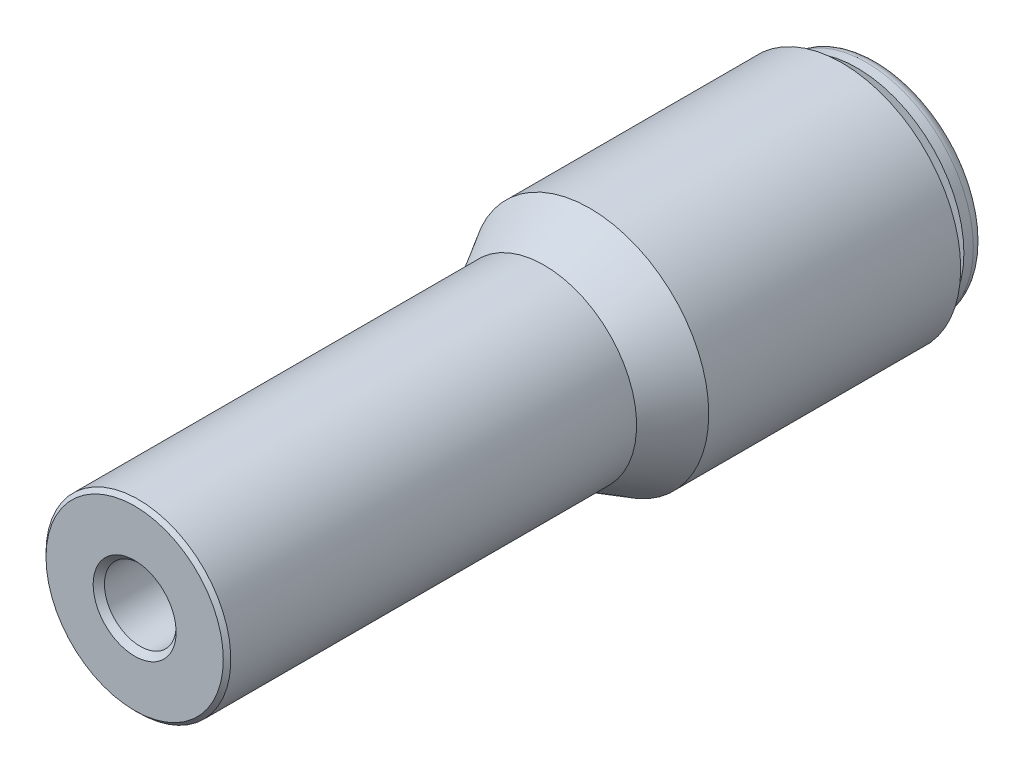
from build123d import *

# Parameters (mm, degrees)
CHAMFER1_SIZE      = 0.381
CUT_EXTRUDE1_REACH = 53.301
SKETCH2_R          = 6.35
SKETCH2_R_2        = 6.223


with BuildPart() as part:
    # Sketch1 → Revolve1 (revolve)
    with BuildSketch(Plane(origin=(0, 0, 0), x_dir=(0, 0, -1), z_dir=(1, 0, 0)), mode=Mode.PRIVATE) as revolve1_sk:
        with BuildLine():
            Line((23.622, 7.2009), (24.257, 7.2009))
            ThreePointArc((24.257, 7.2009), (24.795815367, 6.977715367), (25.019, 6.4389))
            Line((25.019, 6.4389), (25.019, 3.556))
            Line((25.019, 3.556), (24.638, 3.175))
            Line((24.638, 3.175), (4.049888889, 3.175))
            Line((4.049888889, 3.175), (4.049888889, 2.413))
            Line((4.049888889, 2.413), (-25.019, 2.413))
            Line((-25.019, 2.413), (-25.019, 6.35))
            Line((-25.019, 6.35), (2.779888889, 6.35))
            Line((2.779888889, 6.35), (5.639504772, 8.001))
            Line((5.639504772, 8.001), (22.606, 8.001))
            Line((22.606, 8.001), (22.606, 6.48081))
            Line((22.606, 6.48081), (23.622, 6.48081))
            Line((23.622, 6.48081), (23.622, 7.2009))
        make_face()
    revolve(revolve1_sk.sketch.rotate(Axis((0, 0, 0), (0, 0, -1)), 90), axis=Axis((0, 0, 0), (0, 0, -1)))

    # Chamfer1
    chamfer1_edges = [part.edges().sort_by_distance(p)[0] for p in [
        (-6.35, 0, 25.019),
        (-2.413, 0, 25.019),
    ]]
    chamfer(chamfer1_edges, length=CHAMFER1_SIZE)

    # Cut-Extrude1: up to this cone (the profile starts outside it)
    cut_extrude1_end = Plane(origin=(0, 0, 25.019), z_dir=(0, 0, -1)).offset(16.800367261) * Cone(1e-06, 21.362325849, 37.000632739, align=(Align.CENTER, Align.CENTER, Align.MIN), mode=Mode.PRIVATE)
    # Sketch2 → Cut-Extrude1 (cut, up to the surface)
    with BuildSketch(Plane.XY.offset(25.019), mode=Mode.PRIVATE) as cut_extrude1_sk1:
        Circle(SKETCH2_R)
        with Locations(Location((0, 0, 0), (0, 0, 180))):
            Circle(SKETCH2_R_2, mode=Mode.SUBTRACT)
    cut_extrude1_tool1 = extrude(cut_extrude1_sk1.sketch, amount=-CUT_EXTRUDE1_REACH, mode=Mode.PRIVATE) - cut_extrude1_end
    add(cut_extrude1_tool1.solids().sort_by_distance((-6.332039, 0, 25.019))[0], mode=Mode.SUBTRACT)


solid = part.part
